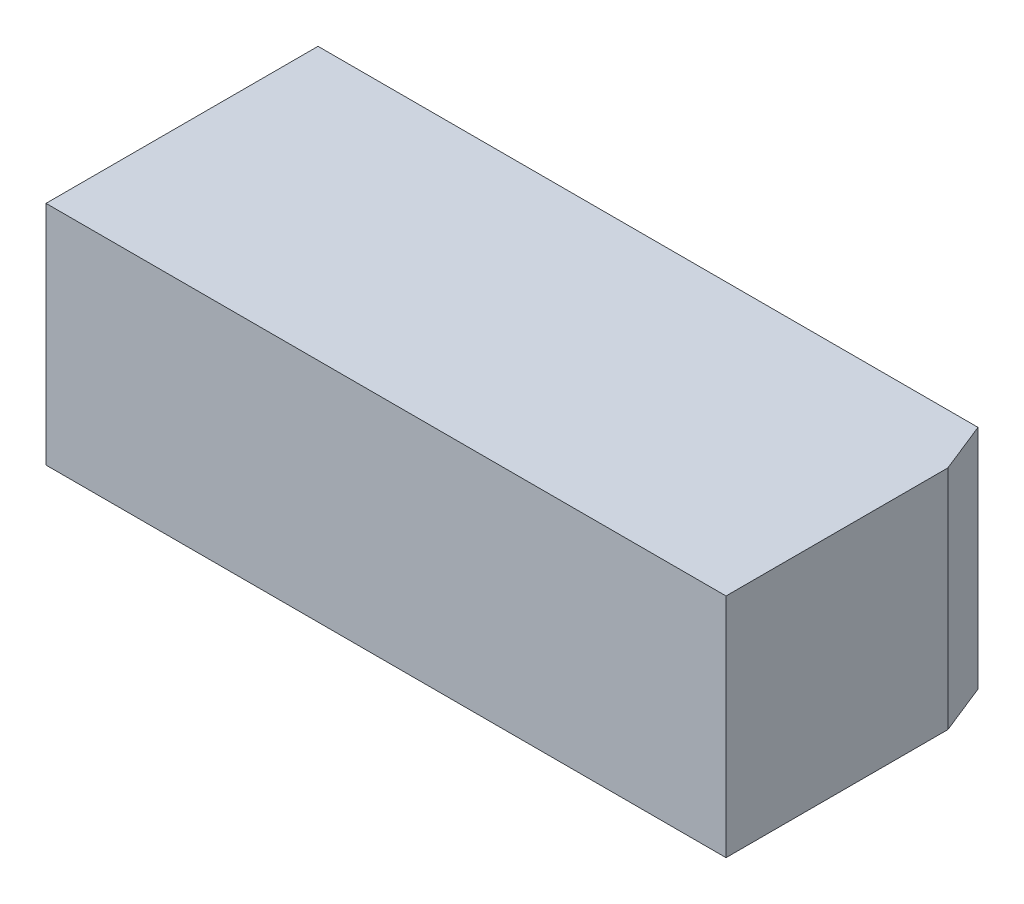
from build123d import *

# Parameters (mm, degrees)
SKETCH1_W              = 15
SKETCH1_H              = 6
MAIN_BODY_DEPTH        = 5
SKETCH3_R              = 1.25
GRIN_HOLE_DEPTH        = 4
SKETCH2_R              = 0.795
MAGNET_HOLES_DEPTH     = 1
SET_SCREW_INDENT_DEPTH = 6
SKETCH5_R              = 0.5
CUT_EXTRUDE1_DEPTH     = 2


with BuildPart() as part:
    # Sketch1 → Main Body (new body)
    with BuildSketch(Plane(origin=(0, 0, 0), x_dir=(1, 0, 0), z_dir=(0, 1, 0))):
        Rectangle(SKETCH1_W, SKETCH1_H)
    extrude(amount=MAIN_BODY_DEPTH)

    # Sketch3 → GRIN Hole (cut)
    with BuildSketch(Plane.XZ):
        with Locations((-4.5, 0)):
            Circle(SKETCH3_R)
    extrude(amount=-GRIN_HOLE_DEPTH, mode=Mode.SUBTRACT)

    # Sketch2 → Magnet Holes (cut)
    with BuildSketch(Plane.XZ):
        with Locations((-6.25, -1.875)):
            Circle(SKETCH2_R)
        with Locations((-6.25, 1.875)):
            Circle(SKETCH2_R)
        with Locations((-1.5, 0)):
            Circle(SKETCH2_R)
    extrude(amount=-MAGNET_HOLES_DEPTH, mode=Mode.SUBTRACT)

    # Sketch4 → Set Screw Indent (cut, through all)
    with BuildSketch(Plane.XZ):
        Polygon((7.058045095, -3), (7.5, -1.895112738), (7.5, -3), align=None)
    extrude(amount=-SET_SCREW_INDENT_DEPTH, mode=Mode.SUBTRACT)

    # Sketch5 → Cut-Extrude1 (cut)
    with BuildSketch(Plane.XZ):
        with Locations((-2, -2)):
            Circle(SKETCH5_R)
    extrude(amount=-CUT_EXTRUDE1_DEPTH, mode=Mode.SUBTRACT)


solid = part.part
